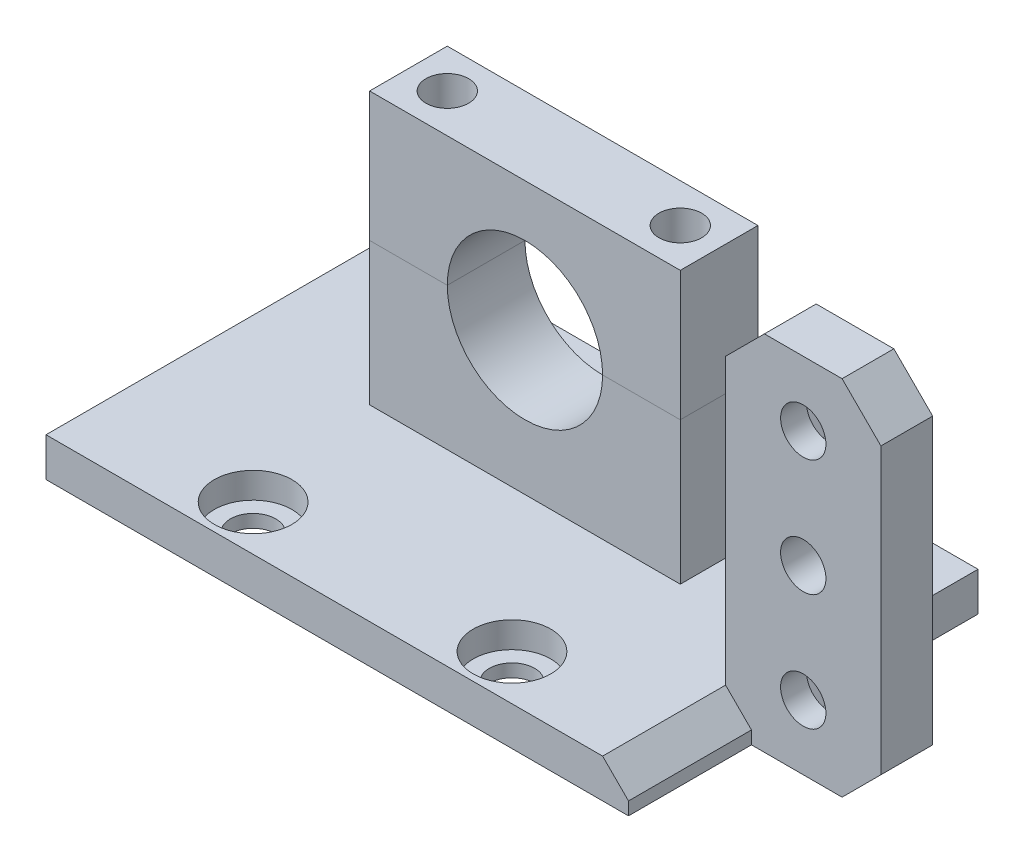
from build123d import *

# Parameters (mm, degrees)
SKETCH1_W                = 45
SKETCH1_H                = 27
BOSS_EXTRUDE1_DEPTH      = 3
CUT_EXTRUDE1_REACH       = 5
SKETCH2_R                = 1.75
SKETCH3_R                = 3
CUT_EXTRUDE2_DEPTH       = 2
BOSS_EXTRUDE2_DEPTH      = 3
BOSS_EXTRUDE3_DEPTH      = 3
SKETCH7_R                = 1.65
CUT_EXTRUDE3_DEPTH       = 15
SKETCH8_W                = 12
SKETCH8_H                = 4
BOSS_EXTRUDE4_DEPTH      = 25
BOSS_EXTRUDE4_DEPTH_BACK = 3
SKETCH9_R                = 1.75
CUT_EXTRUDE4_DEPTH       = 4
CUT_EXTRUDE5_DEPTH       = 2
CHAMFER1_SIZE            = 2
CHAMFER2_SIZE            = 3


with BuildPart() as part:
    # Sketch1 → Boss-Extrude1 (new body)
    with BuildSketch(Plane(origin=(0, 0, 0), x_dir=(1, 0, 0), z_dir=(0, 1, 0))):
        Rectangle(SKETCH1_W, SKETCH1_H)
    extrude(amount=BOSS_EXTRUDE1_DEPTH)

    # Sketch2 → Cut-Extrude1 (cut, up to next)
    with BuildSketch(Plane(origin=(0, 3, 0), x_dir=(1, 0, 0), z_dir=(0, 1, 0)), mode=Mode.PRIVATE) as cut_extrude1_sk1:
        with Locations((-10, 10)):
            Circle(SKETCH2_R)
    cut_extrude1_tool1 = extrude(cut_extrude1_sk1.sketch, amount=-CUT_EXTRUDE1_REACH, mode=Mode.PRIVATE) & part.part
    add(cut_extrude1_tool1.solids().sort_by_distance((-10, 3, -10))[0], mode=Mode.SUBTRACT)
    # Sketch2 → Cut-Extrude1 (cut, up to next)
    with BuildSketch(Plane(origin=(0, 3, 0), x_dir=(1, 0, 0), z_dir=(0, 1, 0)), mode=Mode.PRIVATE) as cut_extrude1_sk2:
        with Locations((10, 10)):
            Circle(SKETCH2_R)
    cut_extrude1_tool2 = extrude(cut_extrude1_sk2.sketch, amount=-CUT_EXTRUDE1_REACH, mode=Mode.PRIVATE) & part.part
    add(cut_extrude1_tool2.solids().sort_by_distance((10, 3, -10))[0], mode=Mode.SUBTRACT)
    # Sketch2 → Cut-Extrude1 (cut, up to next)
    with BuildSketch(Plane(origin=(0, 3, 0), x_dir=(1, 0, 0), z_dir=(0, 1, 0)), mode=Mode.PRIVATE) as cut_extrude1_sk3:
        with Locations((10, -10)):
            Circle(SKETCH2_R)
    cut_extrude1_tool3 = extrude(cut_extrude1_sk3.sketch, amount=-CUT_EXTRUDE1_REACH, mode=Mode.PRIVATE) & part.part
    add(cut_extrude1_tool3.solids().sort_by_distance((10, 3, 10))[0], mode=Mode.SUBTRACT)
    # Sketch2 → Cut-Extrude1 (cut, up to next)
    with BuildSketch(Plane(origin=(0, 3, 0), x_dir=(1, 0, 0), z_dir=(0, 1, 0)), mode=Mode.PRIVATE) as cut_extrude1_sk4:
        with Locations((-10, -10)):
            Circle(SKETCH2_R)
    cut_extrude1_tool4 = extrude(cut_extrude1_sk4.sketch, amount=-CUT_EXTRUDE1_REACH, mode=Mode.PRIVATE) & part.part
    add(cut_extrude1_tool4.solids().sort_by_distance((-10, 3, 10))[0], mode=Mode.SUBTRACT)

    # Sketch3 → Cut-Extrude2 (cut)
    with BuildSketch(Plane(origin=(0, 3, 0), x_dir=(1, 0, 0), z_dir=(0, 1, 0))):
        with Locations((-10, 10)):
            Circle(SKETCH3_R)
        with Locations((10, 10)):
            Circle(SKETCH3_R)
        with Locations((10, -10)):
            Circle(SKETCH3_R)
        with Locations((-10, -10)):
            Circle(SKETCH3_R)
    extrude(amount=-CUT_EXTRUDE2_DEPTH, mode=Mode.SUBTRACT)

    # Sketch5 → Boss-Extrude2 (add, symmetric)
    with BuildSketch(Plane.XY.offset(-4)):
        with BuildLine():
            Line((12, 3), (-12, 3))
            Line((-12, 3), (-12, 14))
            Line((-12, 14), (-6, 14))
            ThreePointArc((-6, 14), (0, 8), (6, 14))
            Line((6, 14), (12, 14))
            Line((12, 14), (12, 3))
        make_face()
    extrude(amount=BOSS_EXTRUDE2_DEPTH, both=True)


with BuildPart() as body_2:
    # Sketch6 → Boss-Extrude3 (new body, symmetric)
    with BuildSketch(Plane.XY.offset(-4)):
        with BuildLine():
            Line((6, 14), (12, 14))
            Line((12, 14), (12, 24))
            Line((12, 24), (-12, 24))
            Line((-12, 24), (-12, 14))
            Line((-12, 14), (-6, 14))
            ThreePointArc((-6, 14), (0, 20), (6, 14))
        make_face()
    extrude(amount=BOSS_EXTRUDE3_DEPTH, both=True)


with BuildPart() as cut_extrude3_tool:
    # Sketch7 → Cut-Extrude3 (new body)
    with BuildSketch(Plane(origin=(0, 24, 0), x_dir=(1, 0, 0), z_dir=(0, 1, 0))):
        with Locations((-9, 4)):
            Circle(SKETCH7_R)
        with Locations((9, 4)):
            Circle(SKETCH7_R)
    extrude(amount=-CUT_EXTRUDE3_DEPTH)


with BuildPart() as part_1:
    add(part.part)

    # Cut-Extrude3: cut by cut_extrude3_tool
    add(cut_extrude3_tool.part, mode=Mode.SUBTRACT)

    # Sketch8 → Boss-Extrude4 (add, two sides)
    with BuildSketch(Plane(origin=(0, 3, 0), x_dir=(1, 0, 0), z_dir=(0, 1, 0))) as boss_extrude4_sk:
        with Locations((26.5, -2)):
            Rectangle(SKETCH8_W, SKETCH8_H)
    extrude(amount=BOSS_EXTRUDE4_DEPTH)
    extrude(boss_extrude4_sk.sketch, amount=-BOSS_EXTRUDE4_DEPTH_BACK)

    # Sketch9 → Cut-Extrude4 (cut)
    with BuildSketch(Plane(origin=(0, 0, 0), x_dir=(-1, 0, 0), z_dir=(0, 0, -1))):
        with Locations((-26.5, 5)):
            Circle(SKETCH9_R)
        with Locations((-26.5, 14)):
            Circle(SKETCH9_R)
        with Locations((-26.5, 23)):
            Circle(SKETCH9_R)
    extrude(amount=-CUT_EXTRUDE4_DEPTH, mode=Mode.SUBTRACT)

    # Sketch10 → Cut-Extrude5 (cut)
    with BuildSketch(Plane(origin=(0, 0, 0), x_dir=(-1, 0, 0), z_dir=(0, 0, -1))):
        Polygon((-29.848631561, 5), (-28.174315781, 2.1), (-24.825684219, 2.1), (-23.151368439, 5), (-24.825684219, 7.9), (-28.174315781, 7.9), align=None)
        Polygon((-28.174315781, 20.1), (-29.848631561, 23), (-28.174315781, 25.9), (-24.825684219, 25.9), (-23.151368439, 23), (-24.825684219, 20.1), align=None)
    extrude(amount=-CUT_EXTRUDE5_DEPTH, mode=Mode.SUBTRACT)

    # Chamfer1
    chamfer1_edges = [part_1.edges().sort_by_distance(p)[0] for p in [
        (22.5, 3, 8.75),
    ]]
    chamfer(chamfer1_edges, length=CHAMFER1_SIZE)

    # Chamfer2
    chamfer2_edges = [part_1.edges().sort_by_distance(p)[0] for p in [
        (32.5, 0, 2),
        (20.5, 28, 2),
        (32.5, 28, 2),
    ]]
    chamfer(chamfer2_edges, length=CHAMFER2_SIZE)


with BuildPart() as body_2_1:
    add(body_2.part)

    # Cut-Extrude3: cut by cut_extrude3_tool
    add(cut_extrude3_tool.part, mode=Mode.SUBTRACT)


solid = Compound([part_1.part, body_2_1.part])
